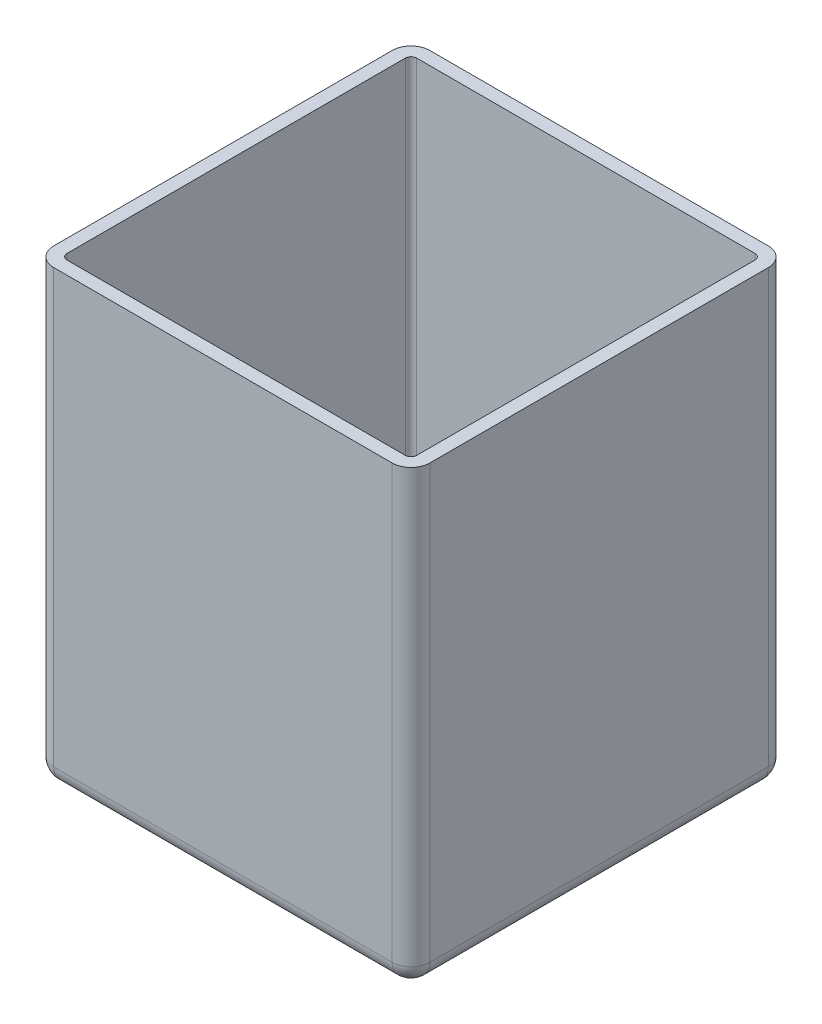
from build123d import *

# Parameters (mm, degrees)
SKETCH1_W           = 200
SKETCH1_H           = 200
BOSS_EXTRUDE1_DEPTH = 240
FILLET1_R           = 10
SHELL1_T            = -7


with BuildPart() as part:
    # Sketch1 → Boss-Extrude1 (new body)
    with BuildSketch(Plane(origin=(0, 0, 0), x_dir=(1, 0, 0), z_dir=(0, 1, 0))):
        Rectangle(SKETCH1_W, SKETCH1_H)
    extrude(amount=BOSS_EXTRUDE1_DEPTH)

    # Fillet1
    fillet1_edges = [part.edges().sort_by_distance(p)[0] for p in [
        (0, 0, -100),
        (100, 0, 0),
        (0, 0, 100),
        (-100, 0, 0),
        (-100, 120, -100),
        (100, 120, -100),
        (100, 120, 100),
        (-100, 120, 100),
    ]]
    fillet(fillet1_edges, radius=FILLET1_R)

    # Shell1
    shell1_openings = [part.faces().sort_by_distance(p)[0] for p in [
        (0, 240, 0),
    ]]
    offset(amount=SHELL1_T, openings=shell1_openings, kind=Kind.INTERSECTION)


solid = part.part
